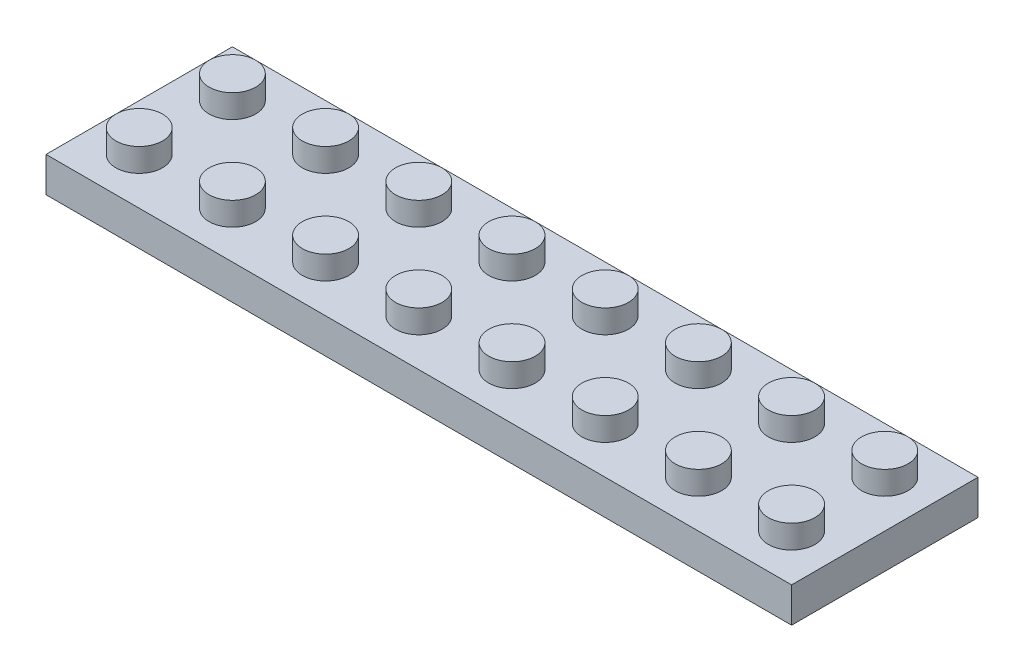
from build123d import *

# Parameters (mm, degrees)
SKETCH1_W           = 64
SKETCH1_H           = 16
BOSS_EXTRUDE1_DEPTH = 3
SKETCH2_R           = 2
BOSS_EXTRUDE2_DEPTH = 2
SHELL1_T            = -1
SKETCH3_R           = 2.8
SKETCH3_R_2         = 1.8
BOSS_EXTRUDE3_DEPTH = 2
LPATTERN1_COUNT     = 7
LPATTERN1_PITCH     = 8


with BuildPart() as part:
    # Sketch1 → Boss-Extrude1 (new body)
    with BuildSketch(Plane(origin=(0, 0, 0), x_dir=(1, 0, 0), z_dir=(0, 1, 0))):
        Rectangle(SKETCH1_W, SKETCH1_H)
    extrude(amount=BOSS_EXTRUDE1_DEPTH)

    # Sketch2 → Boss-Extrude2 (add)
    with BuildSketch(Plane(origin=(0, 3, 0), x_dir=(1, 0, 0), z_dir=(0, 1, 0))):
        with Locations((-28, 4)):
            Circle(SKETCH2_R)
        with Locations((-20, 4)):
            Circle(SKETCH2_R)
        with Locations((-12, 4)):
            Circle(SKETCH2_R)
        with Locations((-4, 4)):
            Circle(SKETCH2_R)
        with Locations((4, 4)):
            Circle(SKETCH2_R)
        with Locations((12, 4)):
            Circle(SKETCH2_R)
        with Locations((20, 4)):
            Circle(SKETCH2_R)
        with Locations((28, 4)):
            Circle(SKETCH2_R)
        with Locations((-20, -4)):
            Circle(SKETCH2_R)
        with Locations((-12, -4)):
            Circle(SKETCH2_R)
        with Locations((-4, -4)):
            Circle(SKETCH2_R)
        with Locations((4, -4)):
            Circle(SKETCH2_R)
        with Locations((12, -4)):
            Circle(SKETCH2_R)
        with Locations((20, -4)):
            Circle(SKETCH2_R)
        with Locations((28, -4)):
            Circle(SKETCH2_R)
        with Locations((-28, -4)):
            Circle(SKETCH2_R)
    extrude(amount=BOSS_EXTRUDE2_DEPTH)

    # Shell1
    shell1_openings = [part.faces().sort_by_distance(p)[0] for p in [
        (0, 0, 0),
    ]]
    offset(amount=SHELL1_T, openings=shell1_openings, kind=Kind.INTERSECTION)

    # Sketch3 → Boss-Extrude3 (add)
    with BuildSketch(Plane.XZ.offset(-2)):
        with Locations((-24, 0)):
            Circle(SKETCH3_R)
        with Locations((-24, 0)):
            Circle(SKETCH3_R_2, mode=Mode.SUBTRACT)
    boss_extrude3 = extrude(amount=BOSS_EXTRUDE3_DEPTH)

    # LPattern1: Boss-Extrude3 ×7
    with Locations(*[(i * LPATTERN1_PITCH, 0, 0) for i in range(1, LPATTERN1_COUNT)]):
        add(boss_extrude3)


solid = part.part
